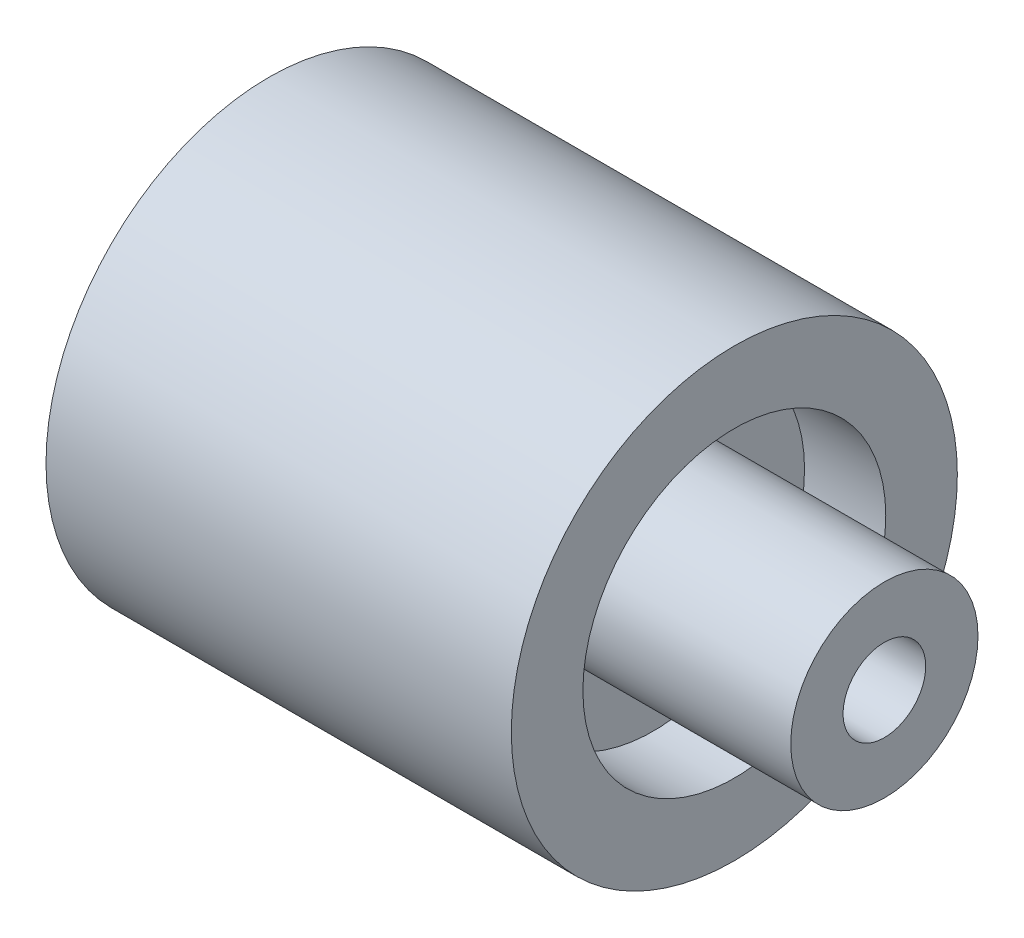
from build123d import *

# Parameters (mm, degrees)
SKETCH_1_R           = 5.5
EXTRUDE_1_DEPTH      = 11
SKETCH_2_R           = 2.7
CUT_EXTRUDE_1_DEPTH  = 9.35
SKETCH_4_R           = 3.4
EXTRUDE_2_DEPTH      = 17.75
SKETCH_5_R           = 1.5
CUT_EXTRUDE_4_DEPTH  = 25.75
SKETCH_6_R           = 8.1
SKETCH_6_R_2         = 5.5
EXTRUDE_4_DEPTH      = 2.95
EXTRUDE_4_DEPTH_BACK = 13.95


with BuildPart() as part:
    # ｽｹｯﾁ1 → ﾎﾞｽ - 押し出し1 (new body)
    with BuildSketch(Plane(origin=(0, 0, 0), x_dir=(0, 0, -1), z_dir=(1, 0, 0))):
        Circle(SKETCH_1_R)
    extrude(amount=EXTRUDE_1_DEPTH)

    # ｽｹｯﾁ2 → ｶｯﾄ - 押し出し1 (cut)
    with BuildSketch(Plane(origin=(11, 0, 0), x_dir=(0, 0, -1), z_dir=(1, 0, 0))):
        Circle(SKETCH_2_R)
    extrude(amount=-CUT_EXTRUDE_1_DEPTH, mode=Mode.SUBTRACT)

    # ｽｹｯﾁ4 → ﾎﾞｽ - 押し出し2 (add)
    with BuildSketch(Plane(origin=(1.65, 0, 0), x_dir=(0, 0, -1), z_dir=(1, 0, 0))):
        Circle(SKETCH_4_R)
    extrude(amount=EXTRUDE_2_DEPTH)

    # ｽｹｯﾁ5 → ｶｯﾄ - 押し出し4 (cut)
    with BuildSketch(Plane(origin=(19.4, 0, 0), x_dir=(0, 0, -1), z_dir=(1, 0, 0))):
        Circle(SKETCH_5_R)
    extrude(amount=-CUT_EXTRUDE_4_DEPTH, mode=Mode.SUBTRACT)

    # ｽｹｯﾁ6 → ﾎﾞｽ - 押し出し4 (add, two sides)
    with BuildSketch(Plane.ZY) as extrude_4_sk:
        Circle(SKETCH_6_R)
        Circle(SKETCH_6_R_2, mode=Mode.SUBTRACT)
    extrude(amount=EXTRUDE_4_DEPTH)
    extrude(extrude_4_sk.sketch, amount=-EXTRUDE_4_DEPTH_BACK)


solid = part.part
